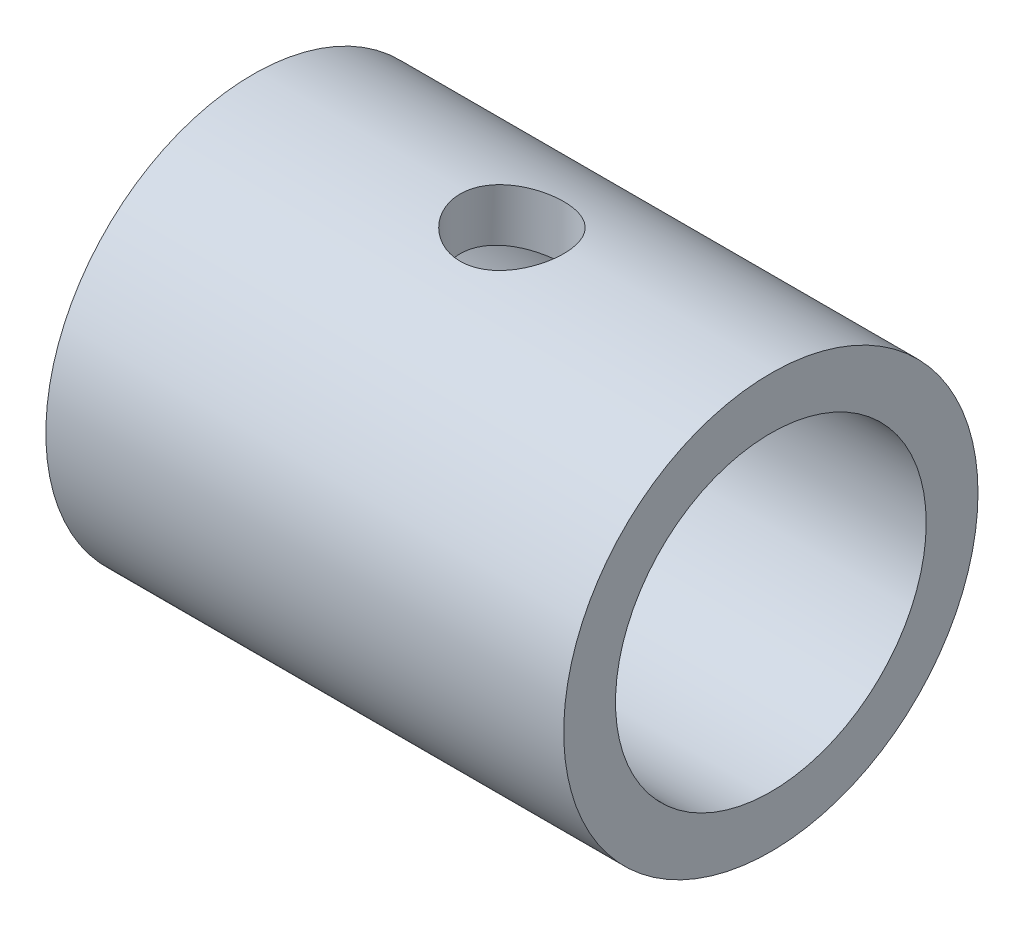
from build123d import *

# Parameters (mm, degrees)
SKETCH1_R           = 8
SKETCH1_R_2         = 6
BOSS_EXTRUDE1_DEPTH = 10
SKETCH2_R           = 2
CUT_EXTRUDE1_DEPTH  = 10


with BuildPart() as part:
    # Sketch1 → Boss-Extrude1 (new body, symmetric)
    with BuildSketch(Plane(origin=(0, 0, 0), x_dir=(0, 0, -1), z_dir=(1, 0, 0))):
        Circle(SKETCH1_R)
        Circle(SKETCH1_R_2, mode=Mode.SUBTRACT)
    extrude(amount=BOSS_EXTRUDE1_DEPTH, both=True)

    # Sketch2 → Cut-Extrude1 (cut, symmetric)
    with BuildSketch(Plane(origin=(0, 0, 0), x_dir=(1, 0, 0), z_dir=(0, 1, 0))):
        Circle(SKETCH2_R)
    extrude(amount=CUT_EXTRUDE1_DEPTH, both=True, mode=Mode.SUBTRACT)


solid = part.part
